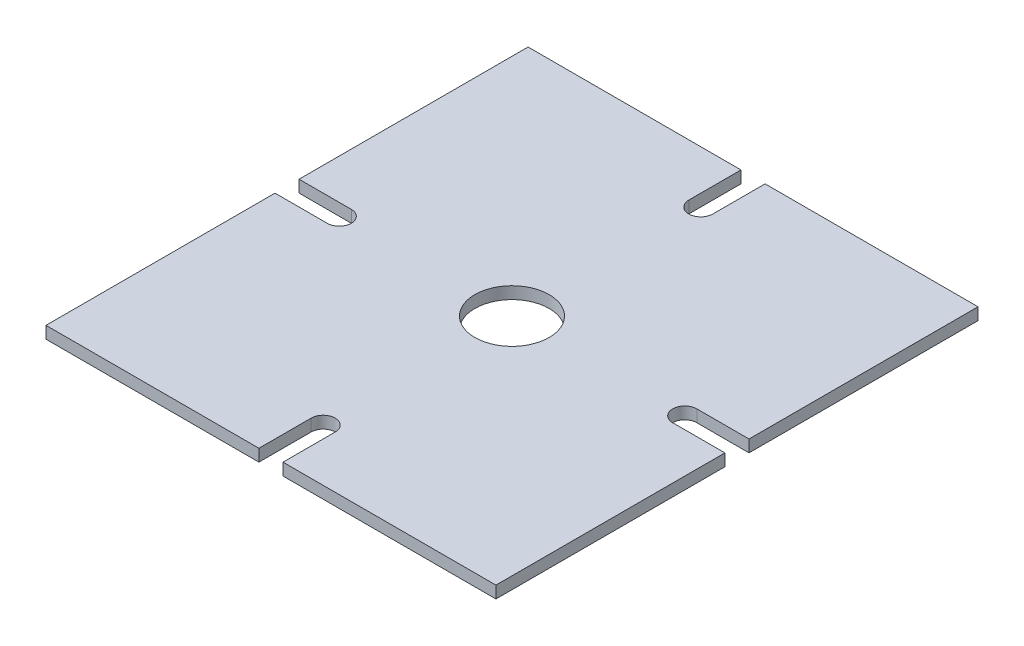
from build123d import *

# Parameters (mm, degrees)
SKETCH1_W           = 112
SKETCH1_H           = 120
BOSS_EXTRUDE1_DEPTH = 3
SKETCH2_R           = 9.25
CUT_EXTRUDE1_DEPTH  = 10
CUT_EXTRUDE2_DEPTH  = 10


with BuildPart() as part:
    # Sketch1 → Boss-Extrude1 (new body)
    with BuildSketch(Plane(origin=(0, 0, 0), x_dir=(1, 0, 0), z_dir=(0, 1, 0))):
        Rectangle(SKETCH1_W, SKETCH1_H)
    extrude(amount=BOSS_EXTRUDE1_DEPTH)

    # Sketch2 → Cut-Extrude1 (cut)
    with BuildSketch(Plane(origin=(0, 3, 0), x_dir=(1, 0, 0), z_dir=(0, 1, 0))):
        Circle(SKETCH2_R)
    extrude(amount=-CUT_EXTRUDE1_DEPTH, mode=Mode.SUBTRACT)

    # Sketch3 → Cut-Extrude2 (cut)
    with BuildSketch(Plane(origin=(0, 3, 0), x_dir=(1, 0, 0), z_dir=(0, 1, 0))):
        with BuildLine():
            Line((-3, -60), (-3, -47))
            ThreePointArc((-3, -47), (0, -44), (3, -47))
            Line((3, -47), (3, -60))
            Line((3, -60), (-3, -60))
        make_face()
        with BuildLine():
            Line((-3, 60), (3, 60))
            Line((3, 60), (3, 47))
            ThreePointArc((3, 47), (0, 44), (-3, 47))
            Line((-3, 47), (-3, 60))
        make_face()
        with BuildLine():
            Line((56, 3), (43, 3))
            ThreePointArc((43, 3), (40, 0), (43, -3))
            Line((43, -3), (56, -3))
            Line((56, -3), (56, 3))
        make_face()
        with BuildLine():
            Line((-43, -3), (-56, -3))
            Line((-56, -3), (-56, 3))
            Line((-56, 3), (-43, 3))
            ThreePointArc((-43, 3), (-40, 0), (-43, -3))
        make_face()
    extrude(amount=-CUT_EXTRUDE2_DEPTH, mode=Mode.SUBTRACT)


solid = part.part
